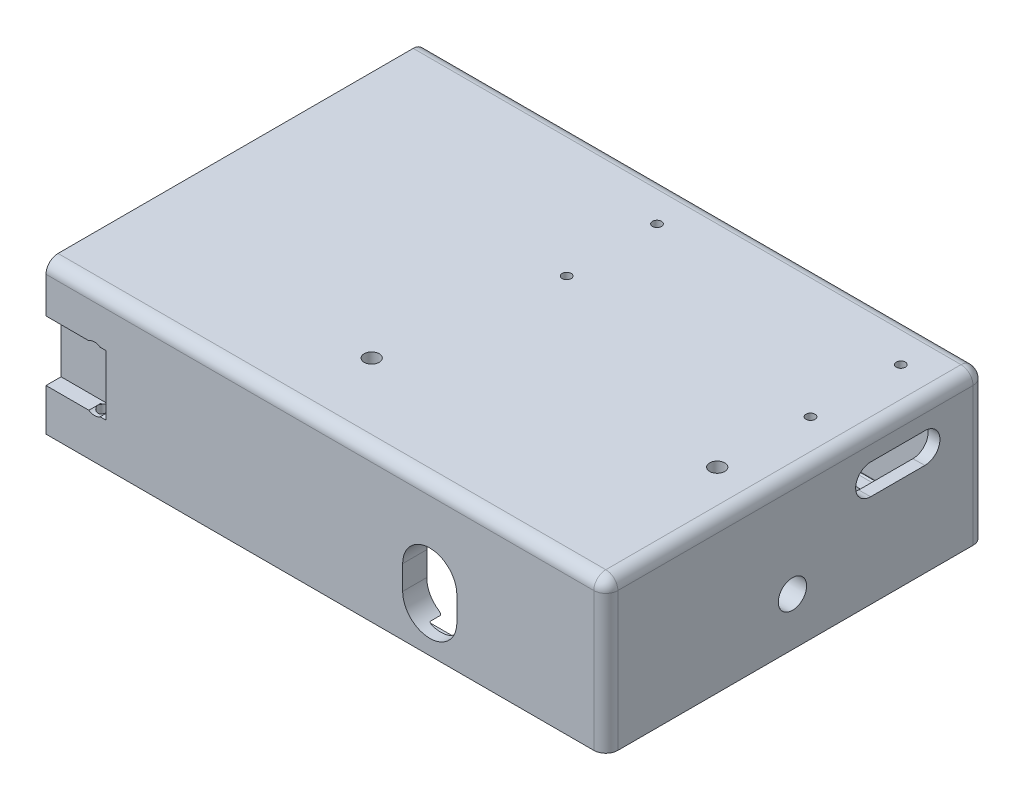
from build123d import *

# Parameters (mm, degrees)
SKETCH1_W               = 95
SKETCH1_H               = 63
BOSS_EXTRUDE2_DEPTH     = 25
SKETCH1_4_W             = 91
SKETCH1_4_H             = 55
CUT_EXTRUDE1_DEPTH      = 23
SKETCH4_W               = 2
SKETCH4_H               = 55
BOSS_EXTRUDE3_DEPTH     = 19
FILLET1_R               = 2
SKETCH5_W               = 2
SKETCH5_H               = 63
CUT_EXTRUDE3_DEPTH      = 117.700471293
SKETCH6_W               = 2.2
SKETCH6_H               = 2.2
CUT_EXTRUDE4_DEPTH      = 85
SKETCH7_W               = 10
SKETCH7_H               = 10
CUT_EXTRUDE5_DEPTH      = 2.5
CUT_EXTRUDE6_DEPTH      = 11.5
CUT_EXTRUDE6_DEPTH_BACK = 1.5
SKETCH8_R               = 0.875
SKETCH9_W               = 10
SKETCH9_H               = 10
CUT_EXTRUDE7_DEPTH      = 2.5
CUT_EXTRUDE8_DEPTH      = 11.5
CUT_EXTRUDE8_DEPTH_BACK = 1.5
SKETCH10_R              = 0.875
CUT_EXTRUDE9_DEPTH      = 2
CUT_EXTRUDE10_DEPTH     = 2
SKETCH13_R              = 0.75
CUT_EXTRUDE11_DEPTH     = 117.288434581
FILLET2_R               = 0.3
CUT_EXTRUDE13_REACH     = 96.256
SKETCH15_W              = 5
SKETCH15_H              = 19
FILLET3_R               = 0.5
CUT_EXTRUDE14_REACH     = 118.7
CUT_EXTRUDE15_REACH     = 118.288
SKETCH16_R              = 1.25
CUT_EXTRUDE16_DEPTH     = 8
CUT_EXTRUDE16_DRAFT     = 1
SKETCH19_R              = 3.75
BOSS_EXTRUDE4_DEPTH     = 5
SKETCH18_3_R            = 2.35
CUT_EXTRUDE17_DEPTH     = 10
CUT_EXTRUDE17_DRAFT     = 2
SKETCH20_R              = 0.75
CUT_EXTRUDE18_DEPTH     = 10
CUT_EXTRUDE19_DEPTH     = 10


with BuildPart() as part:
    # Sketch1 → Boss-Extrude2 (new body)
    with BuildSketch(Plane(origin=(0, 0, 0), x_dir=(1, 0, 0), z_dir=(0, 1, 0))):
        with Locations((47.5, 31.5)):
            Rectangle(SKETCH1_W, SKETCH1_H)
    extrude(amount=BOSS_EXTRUDE2_DEPTH)

    # Sketch1_4 → Cut-Extrude1 (cut)
    with BuildSketch(Plane(origin=(0, 0, 0), x_dir=(1, 0, 0), z_dir=(0, 1, 0))):
        with Locations((47.5, 31.5)):
            Rectangle(SKETCH1_4_W, SKETCH1_4_H)
    extrude(amount=CUT_EXTRUDE1_DEPTH, mode=Mode.SUBTRACT)

    # Sketch4 → Boss-Extrude3 (add)
    with BuildSketch(Plane.XZ.offset(-23)):
        with Locations((30.5, -31.5)):
            Rectangle(SKETCH4_W, SKETCH4_H)
    extrude(amount=BOSS_EXTRUDE3_DEPTH)

    # Fillet1
    fillet1_edges = [part.edges().sort_by_distance(p)[0] for p in [
        (47.5, 25, -63),
        (0, 12.5, -63),
        (0, 25, -31.5),
        (0, 12.5, 0),
        (47.5, 25, 0),
        (95, 12.5, 0),
        (95, 25, -31.5),
        (95, 12.5, -63),
    ]]
    fillet(fillet1_edges, radius=FILLET1_R)

    # Sketch5 → Cut-Extrude3 (cut, through all)
    with BuildSketch(Plane(origin=(0, 0, 0), x_dir=(-1, 0, 0), z_dir=(0, -1, 0))):
        with Locations((-1, 31.5)):
            Rectangle(SKETCH5_W, SKETCH5_H)
    extrude(amount=-CUT_EXTRUDE3_DEPTH, mode=Mode.SUBTRACT)

    # Sketch6 → Cut-Extrude4 (cut)
    with BuildSketch(Plane.ZY.offset(-2)):
        with Locations((-2.9, 1.85)):
            Rectangle(SKETCH6_W, SKETCH6_H)
        with Locations((-60.1, 1.85)):
            Rectangle(SKETCH6_W, SKETCH6_H)
    extrude(amount=-CUT_EXTRUDE4_DEPTH, mode=Mode.SUBTRACT)

    # Sketch7 → Cut-Extrude5 (cut)
    with BuildSketch(Plane(origin=(0, 0, -63), x_dir=(-1, 0, 0), z_dir=(0, 0, -1))):
        with Locations((-7, 12)):
            Rectangle(SKETCH7_W, SKETCH7_H)
    extrude(amount=-CUT_EXTRUDE5_DEPTH, mode=Mode.SUBTRACT)

    # Sketch8 → Cut-Extrude6 (cut, two sides: drawn at the far end of the back side and taken through both)
    with BuildSketch(Plane(origin=(0, 7, 0), x_dir=(1, 0, 0), z_dir=(0, 1, 0)).offset(-CUT_EXTRUDE6_DEPTH_BACK)):
        with Locations((10, 61.5)):
            Circle(SKETCH8_R)
    extrude(amount=CUT_EXTRUDE6_DEPTH + CUT_EXTRUDE6_DEPTH_BACK, mode=Mode.SUBTRACT)

    # Sketch9 → Cut-Extrude7 (cut)
    with BuildSketch(Plane.XY):
        with Locations((7, 12)):
            Rectangle(SKETCH9_W, SKETCH9_H)
    extrude(amount=-CUT_EXTRUDE7_DEPTH, mode=Mode.SUBTRACT)

    # Sketch10 → Cut-Extrude8 (cut, two sides: drawn at the far end of the back side and taken through both)
    with BuildSketch(Plane(origin=(0, 7, 0), x_dir=(1, 0, 0), z_dir=(0, 1, 0)).offset(-CUT_EXTRUDE8_DEPTH_BACK)):
        with Locations((10, 1.5)):
            Circle(SKETCH10_R)
    extrude(amount=CUT_EXTRUDE8_DEPTH + CUT_EXTRUDE8_DEPTH_BACK, mode=Mode.SUBTRACT)

    # Sketch11 → Cut-Extrude9 (cut)
    with BuildSketch(Plane(origin=(0, 0, -63), x_dir=(-1, 0, 0), z_dir=(0, 0, -1))):
        with BuildLine():
            Line((-9.122986176, 7), (-10.8, 7))
            add(Edge.make_bspline(
                [(-10.8, 7), (-9.980201359, 6.395551325), (-9.122986176, 7)],
                knots=[0, 0, 0, 1, 1, 1], degree=2))
        make_face()
        with BuildLine():
            Line((-9.122986176, 17), (-10.8, 17))
            add(Edge.make_bspline(
                [(-10.8, 17), (-9.980201359, 17.604448675), (-9.122986176, 17)],
                knots=[0, 0, 0, 1, 1, 1], degree=2))
        make_face()
    extrude(amount=-CUT_EXTRUDE9_DEPTH, mode=Mode.SUBTRACT)

    # Sketch12 → Cut-Extrude10 (cut)
    with BuildSketch(Plane.XY):
        with BuildLine():
            Line((11, 7), (9.120131213, 7))
            add(Edge.make_bspline(
                [(11, 7), (10.05659536, 6.399803182), (9.120131213, 7)],
                knots=[0, 0, 0, 1, 1, 1], degree=2))
        make_face()
        with BuildLine():
            Line((11, 17), (9.120131213, 17))
            add(Edge.make_bspline(
                [(11, 17), (10.05659536, 17.600196818), (9.120131213, 17)],
                knots=[0, 0, 0, 1, 1, 1], degree=2))
        make_face()
    extrude(amount=-CUT_EXTRUDE10_DEPTH, mode=Mode.SUBTRACT)

    # Sketch13 → Cut-Extrude11 (cut, through all)
    with BuildSketch(Plane(origin=(0, 23, 0), x_dir=(-1, 0, 0), z_dir=(0, -1, 0))):
        with Locations((-47.5, 56)):
            Circle(SKETCH13_R)
        with Locations((-47.5, 41)):
            Circle(SKETCH13_R)
        with Locations((-88, 41)):
            Circle(SKETCH13_R)
        with Locations((-88, 56)):
            Circle(SKETCH13_R)
    extrude(amount=-CUT_EXTRUDE11_DEPTH, mode=Mode.SUBTRACT)

    # Fillet2
    fillet2_edges = [part.edges().sort_by_distance(p)[0] for p in [
        (44.5, 2.95, -4),
        (44.5, 2.95, -1.8),
        (2, 1.85, -1.8),
        (2, 2.95, -2.9),
        (44.5, 2.95, -59),
        (44.5, 0.75, -61.2),
        (44.5, 2.95, -61.2),
        (2, 2.95, -60.1),
        (2, 0.75, -60.1),
        (2, 1.85, -61.2),
        (2, 0.75, -2.9),
        (44.5, 0.75, -1.8),
    ]]
    fillet(fillet2_edges, radius=FILLET2_R)

    # Sketch15 → Cut-Extrude13 (cut, up to next)
    with BuildSketch(Plane.ZY.offset(-29.5), mode=Mode.PRIVATE) as cut_extrude13_sk1:
        with Locations((-6.5, 13.5)):
            Rectangle(SKETCH15_W, SKETCH15_H)
    cut_extrude13_tool1 = extrude(cut_extrude13_sk1.sketch, amount=-CUT_EXTRUDE13_REACH, mode=Mode.PRIVATE) & part.part
    add(cut_extrude13_tool1.solids().sort_by_distance((29.5, 13.5, -6.5))[0], mode=Mode.SUBTRACT)

    # Fillet3
    fillet3_edges = [part.edges().sort_by_distance(p)[0] for p in [
        (31.5, 13.5, -59),
        (29.5, 13.5, -59),
        (31.5, 4, -34),
        (29.5, 4, -34),
        (30.5, 4, -9),
        (30.5, 4, -59),
    ]]
    fillet(fillet3_edges, radius=FILLET3_R)

    # Sketch17 → Cut-Extrude14 (cut, up to next)
    with BuildSketch(Plane.XY, mode=Mode.PRIVATE) as cut_extrude14_sk1:
        with BuildLine():
            Line((70.25, 11), (70.25, 7))
            ThreePointArc((70.25, 7), (65.75, 2.5), (61.25, 7))
            Line((61.25, 7), (61.25, 11))
            ThreePointArc((61.25, 11), (65.75, 15.5), (70.25, 11))
        make_face()
    cut_extrude14_tool1 = extrude(cut_extrude14_sk1.sketch, amount=-CUT_EXTRUDE14_REACH, mode=Mode.PRIVATE) & part.part
    add(cut_extrude14_tool1.solids().sort_by_distance((65.75, 9, 0))[0], mode=Mode.SUBTRACT)

    # Sketch16 → Cut-Extrude15 (cut, up to next)
    with BuildSketch(Plane.XZ.offset(-23), mode=Mode.PRIVATE) as cut_extrude15_sk1:
        with Locations((87.5, -26)):
            Circle(SKETCH16_R)
    cut_extrude15_tool1 = extrude(cut_extrude15_sk1.sketch, amount=-CUT_EXTRUDE15_REACH, mode=Mode.PRIVATE) & part.part
    # Sketch16 → Cut-Extrude15 (cut, up to next)
    with BuildSketch(Plane.XZ.offset(-23), mode=Mode.PRIVATE) as cut_extrude15_sk2:
        with Locations((43.1, -13)):
            Circle(SKETCH16_R)
    cut_extrude15_tool2 = extrude(cut_extrude15_sk2.sketch, amount=-CUT_EXTRUDE15_REACH, mode=Mode.PRIVATE) & part.part
    add(cut_extrude15_tool1.solids().sort_by_distance((87.5, 23, -26))[0], mode=Mode.SUBTRACT)
    add(cut_extrude15_tool2.solids().sort_by_distance((43.1, 23, -13))[0], mode=Mode.SUBTRACT)


with BuildPart() as cut_extrude16_tool:
    # Sketch18 → Cut-Extrude16 (with draft: the straight prism first)
    with BuildSketch(Plane(origin=(95, 0, 0), x_dir=(0, 0, -1), z_dir=(1, 0, 0))):
        with BuildLine():
            Line((44, 15.5), (53, 15.5))
            ThreePointArc((53, 15.5), (55.5, 18), (53, 20.5))
            Line((53, 20.5), (44, 20.5))
            ThreePointArc((44, 20.5), (41.5, 18), (44, 15.5))
        make_face()
    extrude(amount=-CUT_EXTRUDE16_DEPTH)
    # Cut-Extrude16: the draft: its side faces are tilted about the plane it starts from
    cut_extrude16_sides = [cut_extrude16_tool.faces().sort_by_distance(p)[0] for p in [
        (91, 18, -41.5),
        (91, 15.5, -48.5),
        (91, 18, -55.5),
        (91, 20.5, -48.5),
    ]]
    draft(cut_extrude16_sides, Plane(origin=(95, 0, 0), x_dir=(0, 0, -1), z_dir=(1, 0, 0)), CUT_EXTRUDE16_DRAFT)


with BuildPart() as part_1:
    add(part.part)

    # Cut-Extrude16: cut by cut_extrude16_tool
    add(cut_extrude16_tool.part, mode=Mode.SUBTRACT)

    # Sketch19 → Boss-Extrude4 (add)
    with BuildSketch(Plane.ZY.offset(-93)):
        with Locations((-31, 8)):
            Circle(SKETCH19_R)
    extrude(amount=BOSS_EXTRUDE4_DEPTH)


with BuildPart() as cut_extrude17_tool:
    # Sketch18_3 → Cut-Extrude17 (with draft: the straight prism first)
    with BuildSketch(Plane(origin=(95, 0, 0), x_dir=(0, 0, -1), z_dir=(1, 0, 0))):
        with Locations((31, 8)):
            Circle(SKETCH18_3_R)
    extrude(amount=-CUT_EXTRUDE17_DEPTH)
    # Cut-Extrude17: the draft: its side faces are tilted about the plane it starts from
    cut_extrude17_sides = [cut_extrude17_tool.faces().sort_by_distance(p)[0] for p in [
        (90, 8, -28.65),
    ]]
    draft(cut_extrude17_sides, Plane(origin=(95, 0, 0), x_dir=(0, 0, -1), z_dir=(1, 0, 0)), CUT_EXTRUDE17_DRAFT)


with BuildPart() as part_2:
    add(part_1.part)

    # Cut-Extrude17: cut by cut_extrude17_tool
    add(cut_extrude17_tool.part, mode=Mode.SUBTRACT)

    # Sketch20 → Cut-Extrude18 (cut)
    with BuildSketch(Plane(origin=(31.5, 0, 0), x_dir=(0, 0, -1), z_dir=(1, 0, 0))):
        with Locations((56, 21)):
            Circle(SKETCH20_R)
        with Locations((15.5, 21)):
            Circle(SKETCH20_R)
        with Locations((15.5, 6)):
            Circle(SKETCH20_R)
        with Locations((56, 6)):
            Circle(SKETCH20_R)
    extrude(amount=-CUT_EXTRUDE18_DEPTH, mode=Mode.SUBTRACT)

    # Sketch21 → Cut-Extrude19 (cut)
    with BuildSketch(Plane(origin=(0, 0, -63), x_dir=(-1, 0, 0), z_dir=(0, 0, -1))):
        with BuildLine():
            Line((-38, 10.5), (-38, 17.5))
            ThreePointArc((-38, 17.5), (-35, 20.5), (-32, 17.5))
            Line((-32, 17.5), (-32, 10.5))
            ThreePointArc((-32, 10.5), (-35, 7.5), (-38, 10.5))
        make_face()
    extrude(amount=-CUT_EXTRUDE19_DEPTH, mode=Mode.SUBTRACT)


solid = part_2.part
